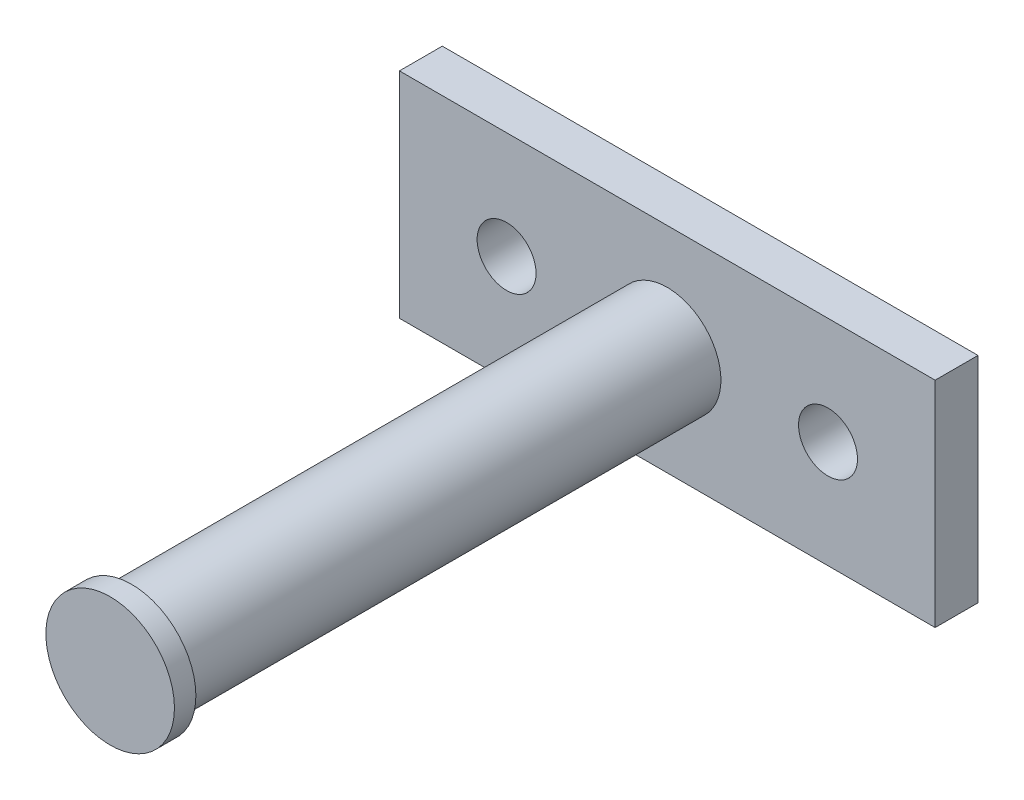
from build123d import *

# Parameters (mm, degrees)
SKETCH1_W           = 50
SKETCH1_H           = 20
SKETCH1_R           = 2.75
BOSS_EXTRUDE1_DEPTH = 4
SKETCH2_R           = 5
BOSS_EXTRUDE2_DEPTH = 50
SKETCH3_R           = 6
BOSS_EXTRUDE3_DEPTH = 2


with BuildPart() as part:
    # Sketch1 → Boss-Extrude1 (new body)
    with BuildSketch(Plane.XY):
        Rectangle(SKETCH1_W, SKETCH1_H)
        with Locations((15, 0)):
            Circle(SKETCH1_R, mode=Mode.SUBTRACT)
        with Locations((-15, 0)):
            Circle(SKETCH1_R, mode=Mode.SUBTRACT)
    extrude(amount=-BOSS_EXTRUDE1_DEPTH)

    # Sketch2 → Boss-Extrude2 (add)
    with BuildSketch(Plane.XY):
        Circle(SKETCH2_R)
    extrude(amount=BOSS_EXTRUDE2_DEPTH)

    # Sketch3 → Boss-Extrude3 (add)
    with BuildSketch(Plane.XY.offset(50)):
        Circle(SKETCH3_R)
    extrude(amount=BOSS_EXTRUDE3_DEPTH)


solid = part.part
